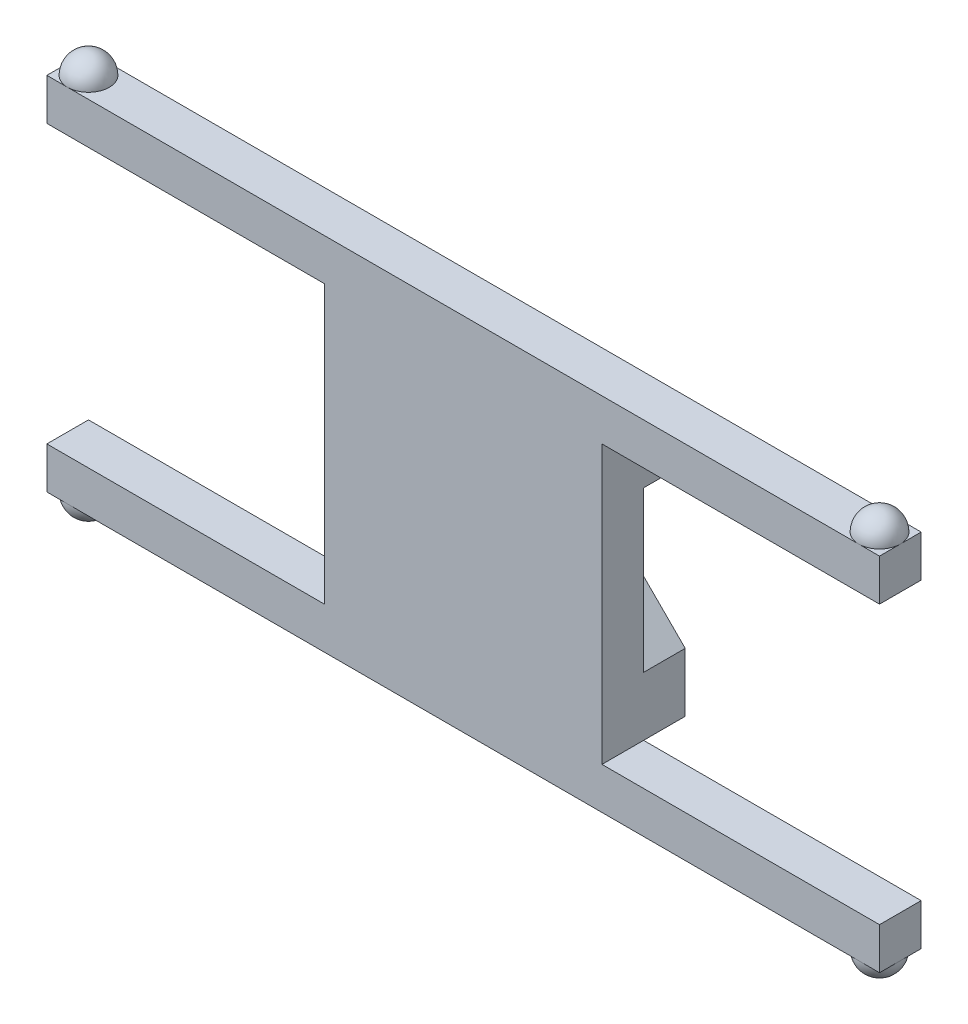
from build123d import *

# Parameters (mm, degrees)
BOSS_EXTRUDE1_DEPTH  = 3
BALL1_REVOLVED_ANGLE = 180
BOSS_EXTRUDE3_DEPTH  = 3


with BuildPart() as part:
    # Sketch1 → Boss-Extrude1 (new body)
    with BuildSketch(Plane.XY):
        Polygon((10, 0), (30, 0), (30, 3), (27, 3), (-27, 3), (-30, 3), (-30, 0), (-10, 0), (-10, -20), (-30, -20), (-30, -23), (-27, -23), (27, -23), (30, -23), (30, -20), (10, -20), align=None)
    extrude(amount=BOSS_EXTRUDE1_DEPTH)

    # ball1 → ball1_revolved (revolve)
    with BuildSketch(Plane(origin=(0, 3, 0), x_dir=(1, 0, 0), z_dir=(0, 1, 0))):
        with BuildLine():
            Line((30, -1.5), (27, -1.5))
            ThreePointArc((27, -1.5), (28.5, 0), (30, -1.5))
        make_face()
    revolve(axis=Axis((30, 3, 1.5), (1, 0, 0)), revolution_arc=BALL1_REVOLVED_ANGLE)

    # Sketch8 → Boss-Extrude3 (add)
    with BuildSketch(Plane(origin=(0, 0, 0), x_dir=(-1, 0, 0), z_dir=(0, 0, -1))):
        Polygon((-5.757359313, 0), (-10, 0), (-10, -4.242640687), (-4.242640687, -10), (0, -5.757359313), align=None)
        Polygon((5.757359313, 0), (0, -5.757359313), (4.242640687, -10), (10, -4.242640687), (10, 0), align=None)
        Polygon((4.242640687, -10), (0, -5.757359313), (-4.242640687, -10), (0, -14.242640687), align=None)
        Polygon((10, -15.757359313), (4.242640687, -10), (0, -14.242640687), (5.757359313, -20), (10, -20), align=None)
        Polygon((0, -14.242640687), (-4.242640687, -10), (-10, -15.757359313), (-10, -20), (-5.757359313, -20), align=None)
    extrude(amount=BOSS_EXTRUDE3_DEPTH)

    # Sketch5 → Revolve4 (revolve)
    with BuildSketch(Plane.XZ.offset(23)):
        with BuildLine():
            ThreePointArc((28.5, 3), (27.439339828, 2.560660172), (27, 1.5))
            Line((27, 1.5), (30, 1.5))
            ThreePointArc((30, 1.5), (29.560660172, 2.560660172), (28.5, 3))
        make_face()
        with BuildLine():
            ThreePointArc((-27, 1.5), (-28.5, 3), (-30, 1.5))
            Line((-30, 1.5), (-27, 1.5))
        make_face()
    revolve(axis=Axis((-30, -23, 1.5), (1, 0, 0)))

    # ball2 → Revolve5 (revolve)
    with BuildSketch(Plane(origin=(0, 3, 0), x_dir=(1, 0, 0), z_dir=(0, 1, 0))):
        with BuildLine():
            Line((-30, -1.5), (-27, -1.5))
            ThreePointArc((-27, -1.5), (-28.5, -3), (-30, -1.5))
        make_face()
    revolve(axis=Axis((-30, 3, 1.5), (1, 0, 0)))


solid = part.part
